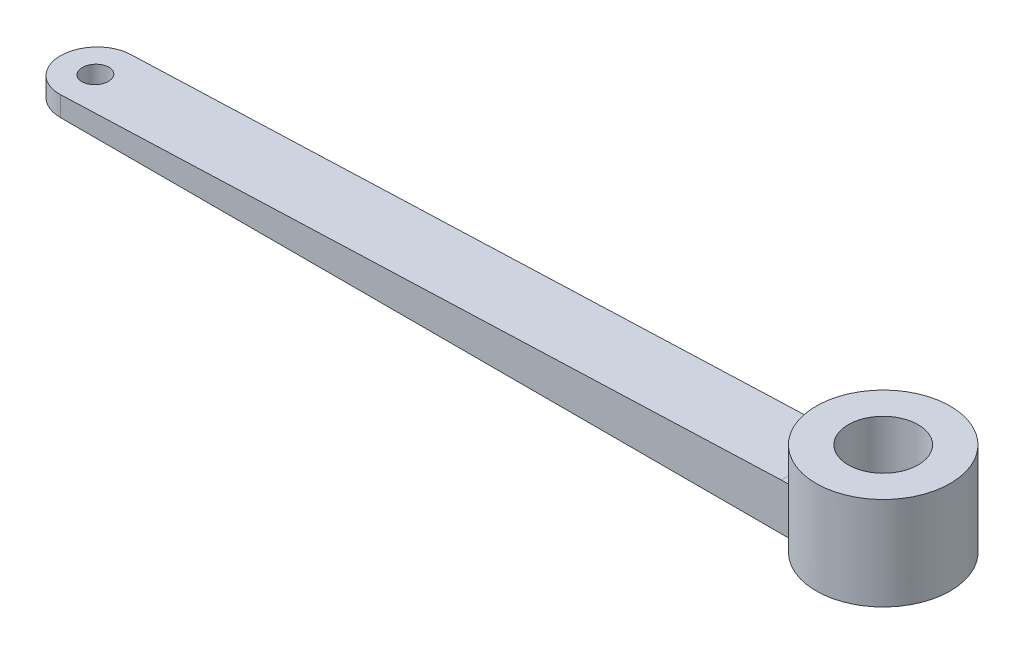
from build123d import *

# Parameters (mm, degrees)
SKETCH1_R               = 9.144
SKETCH1_R_2             = 4.7625
BOSS_EXTRUDE1_DEPTH     = 12.7
SKETCH2_R               = 1.778
BOSS_EXTRUDE2_DEPTH     = 6.35
SKETCH3_R               = 4.7625
CUT_EXTRUDE1_DEPTH      = 13.97
CUT_EXTRUDE3_DEPTH      = 10.144
CUT_EXTRUDE3_DEPTH_BACK = 10.144


with BuildPart() as part:
    # Sketch1 → Boss-Extrude1 (new body)
    with BuildSketch(Plane(origin=(0, 0, 0), x_dir=(1, 0, 0), z_dir=(0, 1, 0))):
        Circle(SKETCH1_R)
        Circle(SKETCH1_R_2, mode=Mode.SUBTRACT)
    extrude(amount=BOSS_EXTRUDE1_DEPTH)

    # Sketch2 → Boss-Extrude2 (add)
    with BuildSketch(Plane(origin=(0, 0, 0), x_dir=(1, 0, 0), z_dir=(0, 1, 0))):
        with BuildLine():
            Line((0, -4.7625), (0, 4.7625))
            Line((0, 4.7625), (-107.442, 4.7625))
            ThreePointArc((-107.442, 4.7625), (-112.2045, 0), (-107.442, -4.7625))
            Line((-107.442, -4.7625), (0, -4.7625))
        make_face()
        with Locations((-107.442, 0)):
            Circle(SKETCH2_R, mode=Mode.SUBTRACT)
    extrude(amount=BOSS_EXTRUDE2_DEPTH)

    # Sketch3 → Cut-Extrude1 (cut)
    with BuildSketch(Plane(origin=(0, 12.7, 0), x_dir=(1, 0, 0), z_dir=(0, 1, 0))):
        Circle(SKETCH3_R)
    extrude(amount=-CUT_EXTRUDE1_DEPTH, mode=Mode.SUBTRACT)

    # Sketch4 → Cut-Extrude3 (cut, two sides)
    with BuildSketch(Plane.XY) as cut_extrude3_sk:
        Polygon((-112.2045, 2.54), (-112.2045, 6.35), (-9.144, 6.35), align=None)
    extrude(amount=CUT_EXTRUDE3_DEPTH, mode=Mode.SUBTRACT)
    extrude(cut_extrude3_sk.sketch, amount=-CUT_EXTRUDE3_DEPTH_BACK, mode=Mode.SUBTRACT)


solid = part.part
